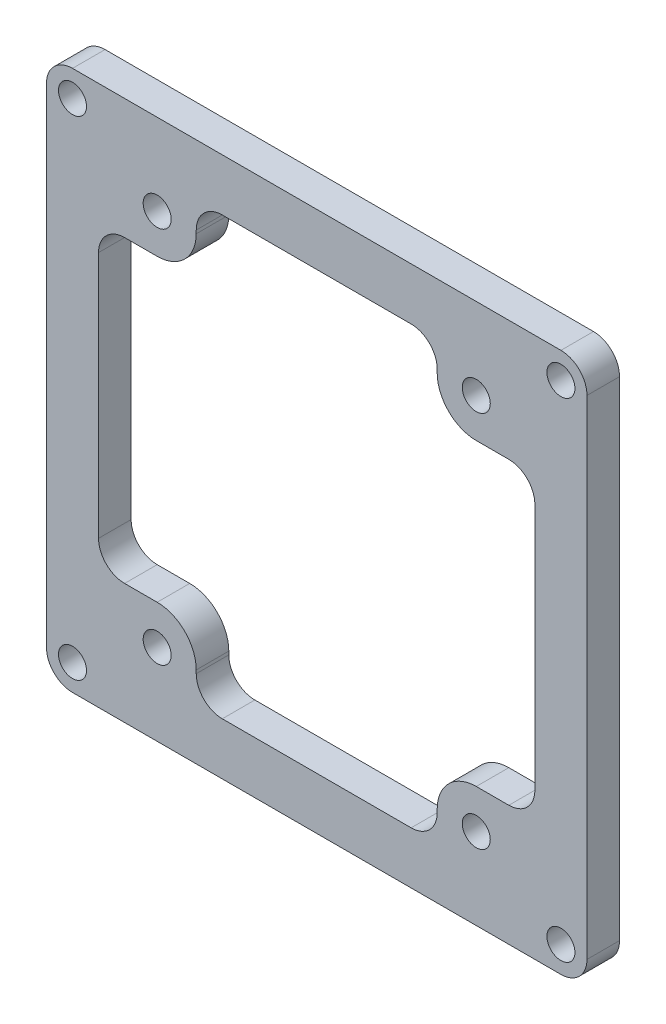
from build123d import *

# Parameters (mm, degrees)
BOSS_EXTRU_1_DEPTH   = 5
D_GAGEMENT_M41_D     = 4.3
D_GAGEMENT_M41_DEPTH = 10
D_GAGEMENT_M41_TIP   = 1.291850331


with BuildPart() as part:
    # Esquisse1 → Boss.-Extru.1 (new body)
    with BuildSketch(Plane.XY):
        with BuildLine():
            Line((-37.5, -41.5), (37.5, -41.5))
            ThreePointArc((37.5, -41.5), (40.328427125, -40.328427125), (41.5, -37.5))
            Line((41.5, -37.5), (41.5, 37.5))
            ThreePointArc((41.5, 37.5), (40.328427125, 40.328427125), (37.5, 41.5))
            Line((37.5, 41.5), (-37.5, 41.5))
            ThreePointArc((-37.5, 41.5), (-40.328427125, 40.328427125), (-41.5, 37.5))
            Line((-41.5, 37.5), (-41.5, -37.5))
            ThreePointArc((-41.5, -37.5), (-40.328427125, -40.328427125), (-37.5, -41.5))
        make_face()
        with BuildLine():
            Line((-14.5, -33.5), (14.5, -33.5))
            ThreePointArc((14.5, -33.5), (17.328427125, -32.328427125), (18.5, -29.5))
            Line((18.5, -29.5), (18.5, -29))
            ThreePointArc((18.5, -29), (20.257359313, -24.757359313), (24.5, -23))
            Line((24.5, -23), (29.5, -23))
            ThreePointArc((29.5, -23), (32.328427125, -21.828427125), (33.5, -19))
            Line((33.5, -19), (33.5, 19))
            ThreePointArc((33.5, 19), (32.328427125, 21.828427125), (29.5, 23))
            Line((29.5, 23), (24.5, 23))
            ThreePointArc((24.5, 23), (20.257359313, 24.757359313), (18.5, 29))
            Line((18.5, 29), (18.5, 29.5))
            ThreePointArc((18.5, 29.5), (17.328427125, 32.328427125), (14.5, 33.5))
            Line((14.5, 33.5), (-14.5, 33.5))
            ThreePointArc((-14.5, 33.5), (-17.328427125, 32.328427125), (-18.5, 29.5))
            Line((-18.5, 29.5), (-18.5, 29))
            ThreePointArc((-18.5, 29), (-20.257359313, 24.757359313), (-24.5, 23))
            Line((-24.5, 23), (-29.5, 23))
            ThreePointArc((-29.5, 23), (-32.328427125, 21.828427125), (-33.5, 19))
            Line((-33.5, 19), (-33.5, -19))
            ThreePointArc((-33.5, -19), (-32.328427125, -21.828427125), (-29.5, -23))
            Line((-29.5, -23), (-24.5, -23))
            ThreePointArc((-24.5, -23), (-20.257359313, -24.757359313), (-18.5, -29))
            Line((-18.5, -29), (-18.5, -29.5))
            ThreePointArc((-18.5, -29.5), (-17.328427125, -32.328427125), (-14.5, -33.5))
        make_face(mode=Mode.SUBTRACT)
    extrude(amount=BOSS_EXTRU_1_DEPTH)

    # Dégagement M41
    with Locations(Plane.XY.offset(5)):
        with Locations((-37.5, 37.5), (37.5, 37.5), (37.5, -37.5), (-37.5, -37.5), (-24.5, 29), (24.5, 29), (24.5, -29), (-24.5, -29)):
            Hole(D_GAGEMENT_M41_D / 2, depth=D_GAGEMENT_M41_DEPTH)
            with Locations((0, 0, -(D_GAGEMENT_M41_DEPTH + D_GAGEMENT_M41_TIP / 2))):  # 118° drill point
                Cone(0, D_GAGEMENT_M41_D / 2, D_GAGEMENT_M41_TIP, mode=Mode.SUBTRACT)


solid = part.part
